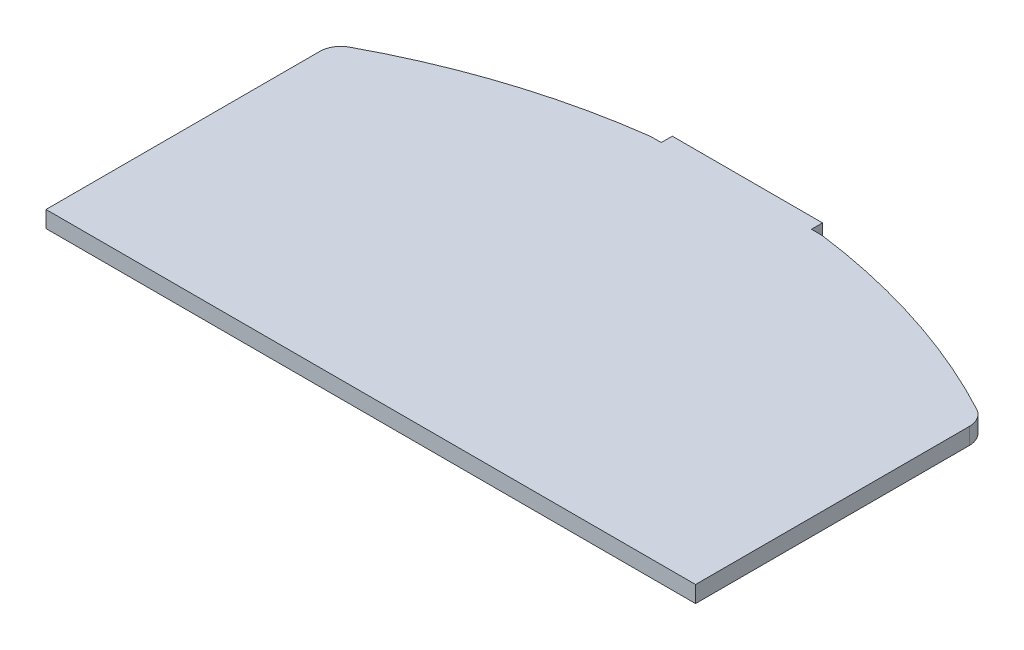
from build123d import *

# Parameters (mm, degrees)
BOSS_EXTRUDE1_DEPTH = 1.5


with BuildPart() as part:
    # Sketch1 → Boss-Extrude1 (new body)
    with BuildSketch(Plane(origin=(0, 0, 0), x_dir=(1, 0, 0), z_dir=(0, 1, 0))):
        with BuildLine():
            Line((29.399956383, -10.909440226), (29.399956383, -35.694042527))
            Line((29.399956383, -35.694042527), (-29.399956383, -35.694042527))
            Line((-29.399956383, -35.694042527), (-29.399956383, -10.909440226))
            ThreePointArc((-29.399956383, -10.909440226), (-29.130344067, -9.933819399), (-28.398023754, -9.235082141))
            ThreePointArc((-28.398023754, -9.235082141), (-18.42847588, -4.996086333), (-7.859761529, -2.616328524))
            ThreePointArc((-7.859761529, -2.616328524), (-7.735749713, -2.604086526), (-7.611202142, -2.6))
            Line((-7.611202142, -2.6), (-6.8, -2.6))
            Line((-6.8, -2.6), (-6.8, -1.6))
            Line((-6.8, -1.6), (6.8, -1.6))
            Line((6.8, -1.6), (6.8, -2.6))
            Line((6.8, -2.6), (7.611202142, -2.6))
            ThreePointArc((7.611202142, -2.6), (7.735749713, -2.604086526), (7.859761529, -2.616328524))
            ThreePointArc((7.859761529, -2.616328524), (18.42847588, -4.996086333), (28.398023754, -9.235082141))
            ThreePointArc((28.398023754, -9.235082141), (29.130344067, -9.933819399), (29.399956383, -10.909440226))
        make_face()
    extrude(amount=BOSS_EXTRUDE1_DEPTH)


solid = part.part
